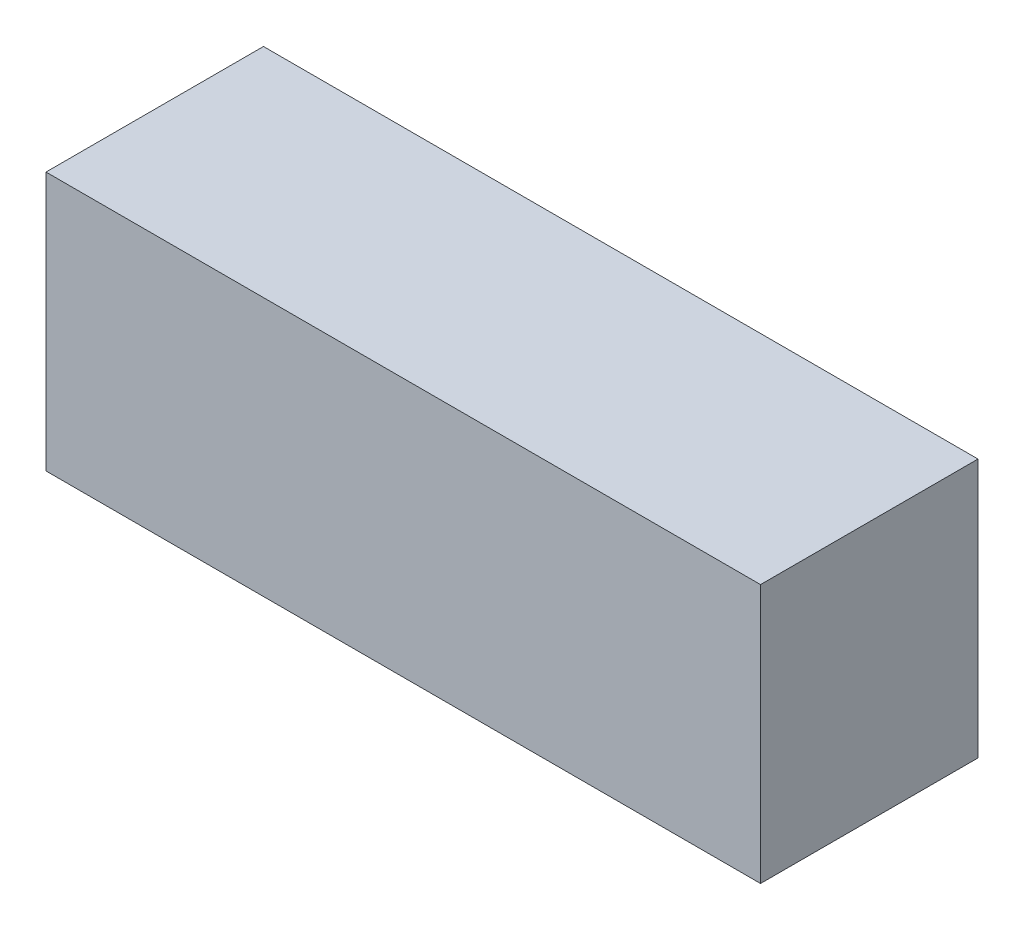
from build123d import *

# Parameters (mm, degrees)
SKETCH1_W           = 52.578
SKETCH1_H           = 19.05
BOSS_EXTRUDE1_DEPTH = 16.002


with BuildPart() as part:
    # Sketch1 → Boss-Extrude1 (new body)
    with BuildSketch(Plane.XY):
        Rectangle(SKETCH1_W, SKETCH1_H)
    extrude(amount=BOSS_EXTRUDE1_DEPTH)


solid = part.part
